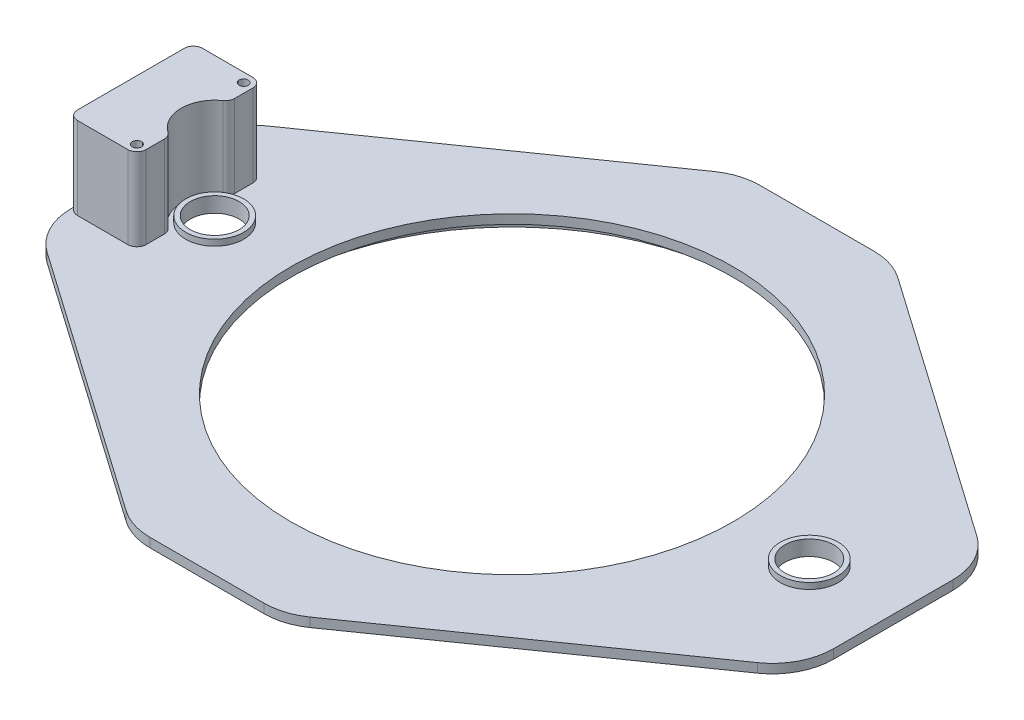
from build123d import *

# Parameters (mm, degrees)
BOSS_EXTRUDE1_DEPTH = 3
SKETCH2_R           = 8
CUT_EXTRUDE1_DEPTH  = 4
SKETCH5_R           = 72.5
CUT_EXTRUDE4_DEPTH  = 4
SKETCH4_R           = 80.5
SKETCH4_R_2         = 78.5
EXTRUDE_THIN1_DEPTH = 5
SKETCH6_R           = 1.5
BOSS_EXTRUDE2_DEPTH = 27
FILLET1_R           = 3
CUT_EXTRUDE5_DEPTH  = 10
FILLET2_R           = 20
SKETCH8_R           = 9.5
SKETCH8_R_2         = 8
EXTRUDE_THIN2_DEPTH = 2


with BuildPart() as part:
    # Sketch1 → Boss-Extrude1 (new body)
    with BuildSketch(Plane(origin=(0, 0, 0), x_dir=(1, 0, 0), z_dir=(0, 1, 0))):
        with BuildLine():
            Line((-115, -100), (115, -100))
            ThreePointArc((115, -100), (122.071067812, -97.071067812), (125, -90))
            Line((125, -90), (125, 90))
            ThreePointArc((125, 90), (122.071067812, 97.071067812), (115, 100))
            Line((115, 100), (-115, 100))
            ThreePointArc((-115, 100), (-122.071067812, 97.071067812), (-125, 90))
            Line((-125, 90), (-125, -90))
            ThreePointArc((-125, -90), (-122.071067812, -97.071067812), (-115, -100))
        make_face()
    extrude(amount=BOSS_EXTRUDE1_DEPTH)

    # Sketch2 → Cut-Extrude1 (cut, through all)
    with BuildSketch(Plane(origin=(0, 3, 0), x_dir=(1, 0, 0), z_dir=(0, 1, 0))):
        with Locations((-97.5, 0)):
            Circle(SKETCH2_R)
    cut_extrude1 = extrude(amount=-CUT_EXTRUDE1_DEPTH, mode=Mode.SUBTRACT)

    # Mirror1: Cut-Extrude1 across plane
    add(cut_extrude1.mirror(Plane(origin=(0, 0, 0), x_dir=(0, 0, 1), z_dir=(1, 0, 0))), mode=Mode.SUBTRACT)

    # Sketch5 → Cut-Extrude4 (cut, through all)
    with BuildSketch(Plane(origin=(0, 0, 0), x_dir=(1, 0, 0), z_dir=(0, 1, 0))):
        Circle(SKETCH5_R)
    extrude(amount=CUT_EXTRUDE4_DEPTH, mode=Mode.SUBTRACT)

    # Sketch4 → Extrude-Thin1 (add)
    with BuildSketch(Plane(origin=(0, 0, 0), x_dir=(1, 0, 0), z_dir=(0, 1, 0))):
        Circle(SKETCH4_R)
        Circle(SKETCH4_R_2, mode=Mode.SUBTRACT)
    extrude(amount=-EXTRUDE_THIN1_DEPTH)

    # Sketch6 → Boss-Extrude2 (add)
    with BuildSketch(Plane(origin=(0, 3, 0), x_dir=(1, 0, 0), z_dir=(0, 1, 0))):
        with BuildLine():
            ThreePointArc((-125, -17.5), (-124.121320344, -19.621320344), (-122, -20.5))
            Line((-122, -20.5), (-105.5, -20.5))
            ThreePointArc((-105.5, -20.5), (-103.378679656, -19.621320344), (-102.5, -17.5))
            Line((-102.5, -17.5), (-102.5, -9.797958971))
            ThreePointArc((-102.5, -9.797958971), (-108.5, 0), (-102.5, 9.797958971))
            Line((-102.5, 9.797958971), (-102.5, 17.5))
            ThreePointArc((-102.5, 17.5), (-103.378679656, 19.621320344), (-105.5, 20.5))
            Line((-105.5, 20.5), (-122, 20.5))
            ThreePointArc((-122, 20.5), (-124.121320344, 19.621320344), (-125, 17.5))
            Line((-125, 17.5), (-125, -17.5))
        make_face()
        with Locations((-105.5, -17.5)):
            Circle(SKETCH6_R, mode=Mode.SUBTRACT)
        with Locations((-105.5, 17.5)):
            Circle(SKETCH6_R, mode=Mode.SUBTRACT)
    extrude(amount=BOSS_EXTRUDE2_DEPTH)

    # Fillet1
    fillet1_edges = [part.edges().sort_by_distance(p)[0] for p in [
        (-102.5, 16.5, 9.797958971),
        (-102.5, 16.5, -9.797958971),
    ]]
    fillet(fillet1_edges, radius=FILLET1_R)

    # Sketch7 → Cut-Extrude5 (cut)
    with BuildSketch(Plane(origin=(0, 3, 0), x_dir=(1, 0, 0), z_dir=(0, 1, 0))):
        with BuildLine():
            Line((-125, 90), (-125, 30))
            Line((-125, 30), (-25, 100))
            Line((-25, 100), (-115, 100))
            ThreePointArc((-115, 100), (-122.071067812, 97.071067812), (-125, 90))
        make_face()
        with BuildLine():
            Line((25, 100), (125, 30))
            Line((125, 30), (125, 90))
            ThreePointArc((125, 90), (122.071067812, 97.071067812), (115, 100))
            Line((115, 100), (25, 100))
        make_face()
        with BuildLine():
            Line((125, -30), (25, -100))
            Line((25, -100), (115, -100))
            ThreePointArc((115, -100), (122.071067812, -97.071067812), (125, -90))
            Line((125, -90), (125, -30))
        make_face()
        with BuildLine():
            ThreePointArc((-125, -90), (-122.071067812, -97.071067812), (-115, -100))
            Line((-115, -100), (-25, -100))
            Line((-25, -100), (-125, -30))
            Line((-125, -30), (-125, -90))
        make_face()
    extrude(amount=-CUT_EXTRUDE5_DEPTH, mode=Mode.SUBTRACT)

    # Fillet2
    fillet2_edges = [part.edges().sort_by_distance(p)[0] for p in [
        (-125, 1.5, 30),
        (-25, 1.5, 100),
        (125, 1.5, 30),
        (25, 1.5, 100),
        (25, 1.5, -100),
        (125, 1.5, -30),
        (-125, 1.5, -30),
        (-25, 1.5, -100),
    ]]
    fillet(fillet2_edges, radius=FILLET2_R)

    # Sketch8 → Extrude-Thin2 (add)
    with BuildSketch(Plane(origin=(0, 3, 0), x_dir=(1, 0, 0), z_dir=(0, 1, 0))):
        with Locations((-97.5, 0)):
            Circle(SKETCH8_R)
        with Locations((-97.5, 0)):
            Circle(SKETCH8_R_2, mode=Mode.SUBTRACT)
        with Locations((97.5, 0)):
            Circle(SKETCH8_R)
        with Locations((97.5, 0)):
            Circle(SKETCH8_R_2, mode=Mode.SUBTRACT)
    extrude(amount=EXTRUDE_THIN2_DEPTH)


solid = part.part
